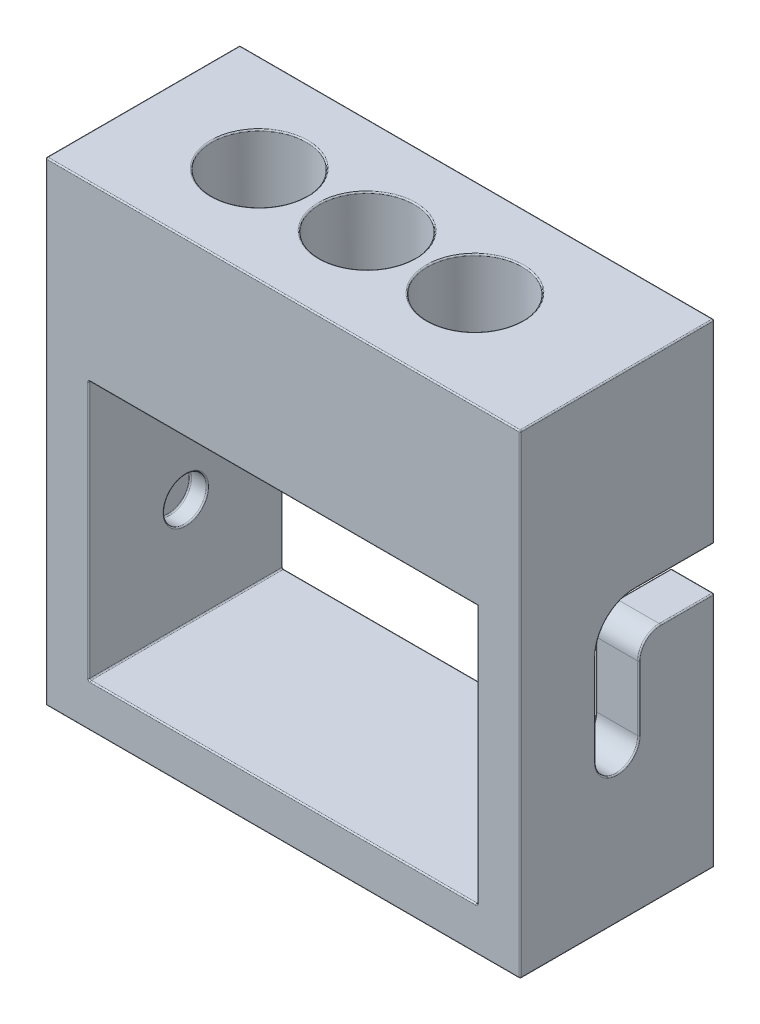
from build123d import *

# Parameters (mm, degrees)
SKETCH1_W           = 114.3
SKETCH1_H           = 76.2
BOSS_EXTRUDE1_DEPTH = 28.575
SKETCH2_R           = 13.97
CUT_EXTRUDE1_DEPTH  = 88.9
SKETCH3_R           = 6.35
CUT_EXTRUDE2_DEPTH  = 132.08
SKETCH4_W           = 114.3
SKETCH4_H           = 44.45
CUT_EXTRUDE3_DEPTH  = 19.05
CUT_EXTRUDE4_DEPTH  = 25.4
FILLET1_R           = 0.381


with BuildPart() as part:
    # Sketch1 → Boss-Extrude1 (new body, symmetric)
    with BuildSketch(Plane.XY):
        Polygon((88.9, 0), (139.7, 0), (139.7, 139.7), (0, 139.7), (0, 0), (12.7, 0), align=None)
        with Locations((69.85, 50.8)):
            Rectangle(SKETCH1_W, SKETCH1_H, mode=Mode.SUBTRACT)
    extrude(amount=BOSS_EXTRUDE1_DEPTH, both=True)

    # Sketch2 → Cut-Extrude1 (cut)
    with BuildSketch(Plane(origin=(0, 139.7, 0), x_dir=(1, 0, 0), z_dir=(0, 1, 0))):
        with Locations((66.04, 0)):
            Circle(SKETCH2_R)
        with Locations((34.29, 0)):
            Circle(SKETCH2_R)
        with Locations((97.79, 0)):
            Circle(SKETCH2_R)
    extrude(amount=-CUT_EXTRUDE1_DEPTH, mode=Mode.SUBTRACT)

    # Sketch3 → Cut-Extrude2 (cut)
    with BuildSketch(Plane(origin=(139.7, 0, 0), x_dir=(0, 0, -1), z_dir=(1, 0, 0))):
        with Locations((0, 44.45)):
            Circle(SKETCH3_R)
    extrude(amount=-CUT_EXTRUDE2_DEPTH, mode=Mode.SUBTRACT)

    # Sketch4 → Cut-Extrude3 (cut)
    with BuildSketch(Plane.XZ.offset(-88.9)):
        with Locations((69.85, 0)):
            Rectangle(SKETCH4_W, SKETCH4_H)
    extrude(amount=-CUT_EXTRUDE3_DEPTH, mode=Mode.SUBTRACT)

    # Sketch5 → Cut-Extrude4 (cut)
    with BuildSketch(Plane(origin=(139.7, 0, 0), x_dir=(0, 0, -1), z_dir=(1, 0, 0))):
        with BuildLine():
            Line((-6.35, 44.45), (-6.35, 71.12))
            ThreePointArc((-6.35, 71.12), (-3.002230509, 79.202230509), (5.08, 82.55))
            Line((5.08, 82.55), (28.575, 82.55))
            Line((28.575, 82.55), (28.575, 69.85))
            Line((28.575, 69.85), (12.7, 69.85))
            ThreePointArc((12.7, 69.85), (8.209871939, 67.990128061), (6.35, 63.5))
            Line((6.35, 63.5), (6.35, 44.45))
            ThreePointArc((6.35, 44.45), (0, 38.1), (-6.35, 44.45))
        make_face()
    extrude(amount=-CUT_EXTRUDE4_DEPTH, mode=Mode.SUBTRACT)

    # Fillet1
    fillet1_edges = [part.edges().sort_by_distance(p)[0] for p in [
        (127, 85.725, -28.575),
        (127, 88.9, -25.4),
        (69.85, 88.9, -28.575),
        (127, 41.275, -28.575),
        (127, 82.55, -16.8275),
        (127, 79.202230509, 3.002230509),
        (127, 57.785, 6.35),
        (139.7, 53.975, -6.35),
        (139.7, 67.990128061, -8.209871939),
        (139.7, 69.85, -20.6375),
        (139.7, 82.55, -16.8275),
        (139.7, 79.202230509, 3.002230509),
        (139.7, 57.785, 6.35),
        (133.35, 69.85, -28.575),
        (127, 53.975, -6.35),
        (69.85, 88.9, -22.225),
        (12.7, 107.95, 0),
        (69.85, 107.95, -22.225),
        (12.7, 98.425, -22.225),
        (127, 98.425, -22.225),
        (12.7, 98.425, 22.225),
        (83.82, 107.95, 0),
        (20.32, 107.95, 0),
        (52.07, 107.95, 0),
        (139.7, 38.1, 0),
        (7.62, 44.45, 6.35),
        (12.7, 44.45, 6.35),
        (127, 38.1, 0),
        (83.82, 139.7, 0),
        (20.32, 139.7, 0),
        (52.07, 139.7, 0),
        (12.7, 50.8, -28.575),
        (69.85, 12.7, -28.575),
        (127, 50.8, 28.575),
        (69.85, 88.9, 28.575),
        (12.7, 50.8, 28.575),
        (69.85, 12.7, 28.575),
        (127, 12.7, 0),
        (12.7, 12.7, 0),
        (12.7, 88.9, -25.4),
        (12.7, 88.9, 25.4),
        (139.7, 111.125, -28.575),
        (139.7, 34.925, -28.575),
        (69.85, 139.7, -28.575),
        (0, 69.85, 28.575),
        (69.85, 0, 28.575),
        (139.7, 69.85, 28.575),
        (69.85, 139.7, 28.575),
        (0, 139.7, 0),
        (139.7, 139.7, 0),
        (139.7, 0, 0),
        (127, 67.990128061, -8.209871939),
        (127, 69.85, -20.6375),
    ]]
    fillet(fillet1_edges, radius=FILLET1_R)


solid = part.part
